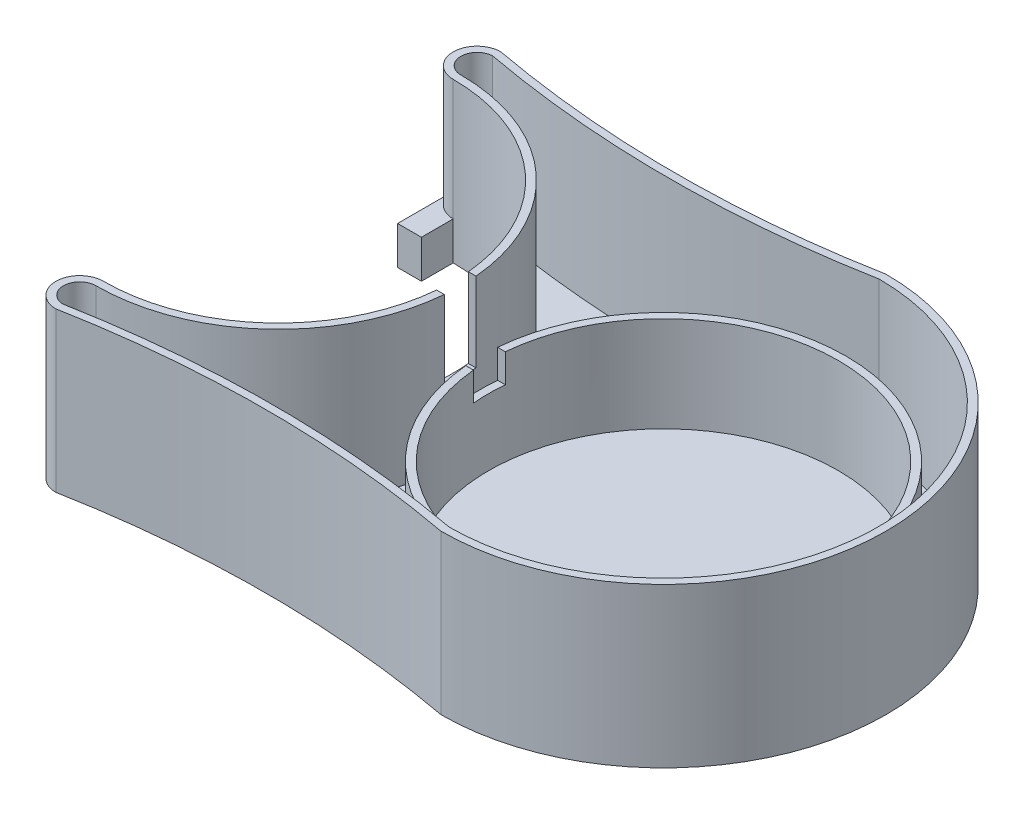
from build123d import *

# Parameters (mm, degrees)
CROQUIS1_R              = 27.5
SALIENTE_EXTRUIR1_DEPTH = 25
VACIADO3_T              = -1.2
CROQUIS5_R              = 29.5
CORTAR_EXTRUIR1_DEPTH   = 8
CROQUIS6_R              = 27.5
SALIENTE_EXTRUIR4_DEPTH = 2
CROQUIS7_W              = 3.75
CROQUIS7_H              = 5
SALIENTE_EXTRUIR5_DEPTH = 25
CORTAR_EXTRUIR2_DEPTH   = 19
CROQUIS9_W              = 14.993348068
CROQUIS9_H              = 5
CORTAR_EXTRUIR3_DEPTH   = 12.5


with BuildPart() as part:
    # Croquis1 → Saliente-Extruir1 (new body)
    with BuildSketch(Plane(origin=(0, 0, 0), x_dir=(1, 0, 0), z_dir=(0, 1, 0))):
        with BuildLine():
            ThreePointArc((-23.07129847, -27.5), (4.42870153, 0), (-23.07129847, 27.5))
            ThreePointArc((-23.07129847, 27.5), (-26.82129847, 31.25), (-23.07129847, 35))
            ThreePointArc((-23.07129847, 35), (7.214350765, 32.196730702), (37.5, 35))
            ThreePointArc((37.5, 35), (72.5, 0), (37.5, -35))
            ThreePointArc((37.5, -35), (7.214350765, -32.196730702), (-23.07129847, -35))
            ThreePointArc((-23.07129847, -35), (-26.82129847, -31.25), (-23.07129847, -27.5))
        make_face()
        with Locations((37.5, 0)):
            Circle(CROQUIS1_R, mode=Mode.SUBTRACT)
    extrude(amount=SALIENTE_EXTRUIR1_DEPTH)

    # Vaciado3
    vaciado3_openings = [part.faces().sort_by_distance(p)[0] for p in [
        (6.28580102, 25, 0),
    ]]
    offset(amount=VACIADO3_T, openings=vaciado3_openings, kind=Kind.INTERSECTION)

    # Croquis5 → Cortar-Extruir1 (cut)
    with BuildSketch(Plane(origin=(0, 25, 0), x_dir=(1, 0, 0), z_dir=(0, 1, 0))):
        with Locations((37.5, 0)):
            Circle(CROQUIS5_R)
    extrude(amount=-CORTAR_EXTRUIR1_DEPTH, mode=Mode.SUBTRACT)

    # Croquis6 → Saliente-Extruir4 (add)
    with BuildSketch(Plane.XZ):
        with Locations((37.5, 0)):
            Circle(CROQUIS6_R)
    extrude(amount=-SALIENTE_EXTRUIR4_DEPTH)

    # Croquis9 → Cortar-Extruir3 (cut)
    with BuildSketch(Plane(origin=(0, 25, 0), x_dir=(1, 0, 0), z_dir=(0, 1, 0))):
        with Locations((7.932233181, 0)):
            Rectangle(CROQUIS9_W, CROQUIS9_H)
    extrude(amount=-CORTAR_EXTRUIR3_DEPTH, mode=Mode.SUBTRACT)


with BuildPart() as body_2:
    # Croquis7 → Saliente-Extruir5 (new body)
    with BuildSketch(Plane(origin=(0, 25, 0), x_dir=(1, 0, 0), z_dir=(0, 1, 0))):
        with BuildLine():
            ThreePointArc((-26.82129847, -31.25), (-25.7229489, -28.598349571), (-23.07129847, -27.5))
            Line((-23.07129847, -27.5), (-23.07129847, -22.5))
            Line((-23.07129847, -22.5), (-26.82129847, -22.5))
            Line((-26.82129847, -22.5), (-26.82129847, -27.5))
            Line((-26.82129847, -27.5), (-26.82129847, -31.25))
        make_face()
        with BuildLine():
            ThreePointArc((-23.07129847, 27.5), (-25.7229489, 28.598349571), (-26.82129847, 31.25))
            Line((-26.82129847, 31.25), (-26.82129847, 27.5))
            Line((-26.82129847, 27.5), (-23.07129847, 27.5))
        make_face()
        with Locations((-24.94629847, 25)):
            Rectangle(CROQUIS7_W, CROQUIS7_H)
    extrude(amount=-SALIENTE_EXTRUIR5_DEPTH)

    # Croquis8 → Cortar-Extruir2 (cut)
    with BuildSketch(Plane(origin=(0, 25, 0), x_dir=(1, 0, 0), z_dir=(0, 1, 0))):
        with BuildLine():
            ThreePointArc((-23.07129847, 27.5), (-25.7229489, 28.598349571), (-26.82129847, 31.25))
            Line((-26.82129847, 31.25), (-26.82129847, 22.5))
            Line((-26.82129847, 22.5), (-23.07129847, 22.5))
            Line((-23.07129847, 22.5), (-23.07129847, 27.5))
        make_face()
        with BuildLine():
            Line((-23.07129847, -22.5), (-26.82129847, -22.5))
            Line((-26.82129847, -22.5), (-26.82129847, -31.25))
            ThreePointArc((-26.82129847, -31.25), (-25.7229489, -28.598349571), (-23.07129847, -27.5))
            Line((-23.07129847, -27.5), (-23.07129847, -22.5))
        make_face()
    extrude(amount=-CORTAR_EXTRUIR2_DEPTH, mode=Mode.SUBTRACT)


solid = Compound([part.part, body_2.part])
